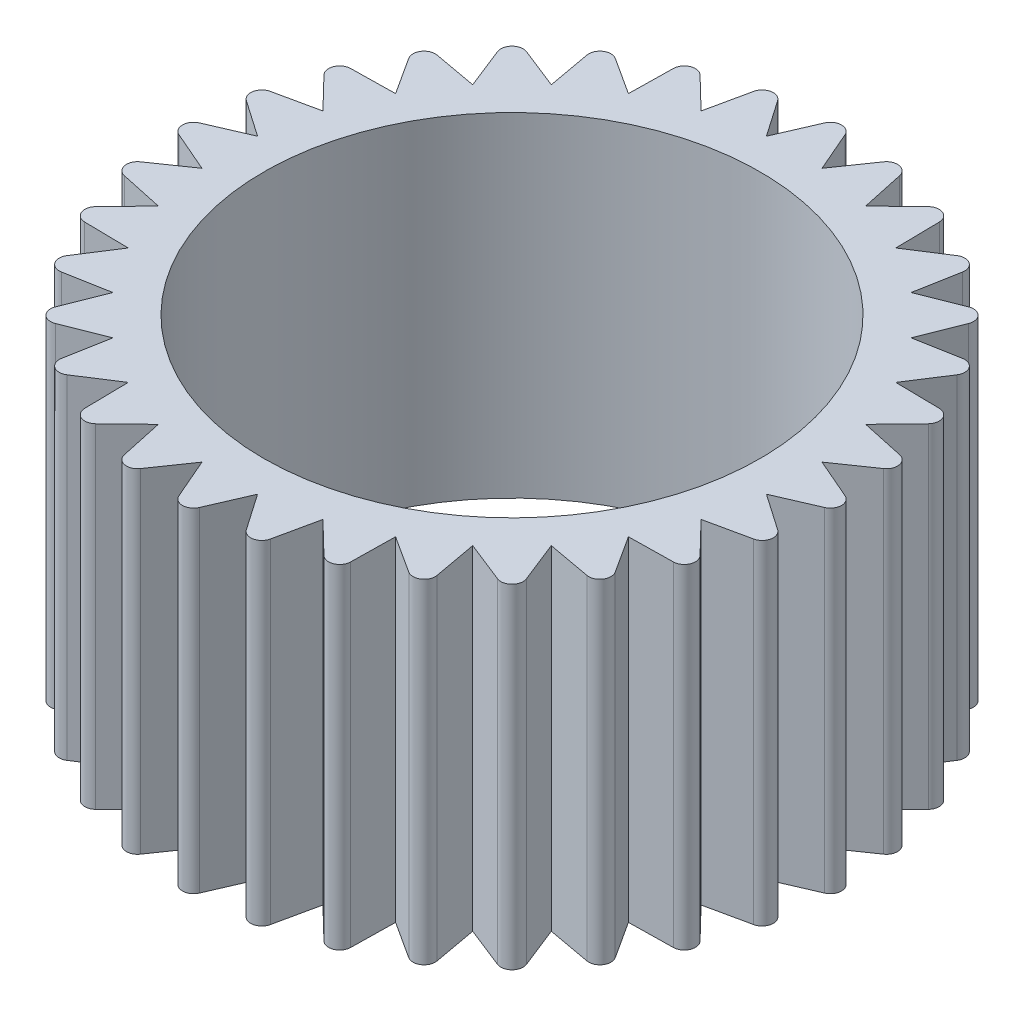
from build123d import *

# Parameters (mm, degrees)
SKETCH1_R           = 11.15
BOSS_EXTRUDE1_DEPTH = 15
FILLET1_R           = 0.5


with BuildPart() as part:
    # Sketch1 → Boss-Extrude1 (new body)
    with BuildSketch(Plane(origin=(0, 0, 0), x_dir=(1, 0, 0), z_dir=(0, 1, 0))):
        Polygon((0, 15.55956659), (-1.24854043, 12.676643718), (-3.035520856, 15.260593881), (-3.69764058, 12.189487409), (-5.954388349, 14.375165107), (-6.004642477, 11.233895935), (-8.644432036, 12.9373068), (-8.080889331, 9.84659214), (-11.002275048, 11.002275048), (-9.84659214, 8.080889331), (-12.9373068, 8.644432036), (-11.233895935, 6.004642477), (-14.375165107, 5.954388349), (-12.189487409, 3.69764058), (-15.260593881, 3.035520856), (-12.676643718, 1.24854043), (-15.55956659, 0), (-12.676643718, -1.24854043), (-15.260593881, -3.035520856), (-12.189487409, -3.69764058), (-14.375165107, -5.954388349), (-11.233895935, -6.004642477), (-12.9373068, -8.644432036), (-9.84659214, -8.080889331), (-11.002275048, -11.002275048), (-8.080889331, -9.84659214), (-8.644432036, -12.9373068), (-6.004642477, -11.233895935), (-5.954388349, -14.375165107), (-3.69764058, -12.189487409), (-3.035520856, -15.260593881), (-1.24854043, -12.676643718), (0, -15.55956659), (1.24854043, -12.676643718), (3.035520856, -15.260593881), (3.69764058, -12.189487409), (5.954388349, -14.375165107), (6.004642477, -11.233895935), (8.644432036, -12.9373068), (8.080889331, -9.84659214), (11.002275048, -11.002275048), (9.84659214, -8.080889331), (12.9373068, -8.644432036), (11.233895935, -6.004642477), (14.375165107, -5.954388349), (12.189487409, -3.69764058), (15.260593881, -3.035520856), (12.676643718, -1.24854043), (15.55956659, 0), (12.676643718, 1.24854043), (15.260593881, 3.035520856), (12.189487409, 3.69764058), (14.375165107, 5.954388349), (11.233895935, 6.004642477), (12.9373068, 8.644432036), (9.84659214, 8.080889331), (11.002275048, 11.002275048), (8.080889331, 9.84659214), (8.644432036, 12.9373068), (6.004642477, 11.233895935), (5.954388349, 14.375165107), (3.69764058, 12.189487409), (3.035520856, 15.260593881), (1.24854043, 12.676643718), align=None)
        Circle(SKETCH1_R, mode=Mode.SUBTRACT)
    extrude(amount=BOSS_EXTRUDE1_DEPTH)

    # Fillet1
    fillet1_edges = [part.edges().sort_by_distance(p)[0] for p in [
        (0, 7.5, -15.55956659),
        (3.035520856, 7.5, -15.260593881),
        (5.954388349, 7.5, -14.375165107),
        (8.644432036, 7.5, -12.9373068),
        (11.002275048, 7.5, -11.002275048),
        (12.9373068, 7.5, -8.644432036),
        (14.375165107, 7.5, -5.954388349),
        (15.260593881, 7.5, -3.035520856),
        (15.55956659, 7.5, 0),
        (15.260593881, 7.5, 3.035520856),
        (14.375165107, 7.5, 5.954388349),
        (12.9373068, 7.5, 8.644432036),
        (11.002275048, 7.5, 11.002275048),
        (8.644432036, 7.5, 12.9373068),
        (5.954388349, 7.5, 14.375165107),
        (3.035520856, 7.5, 15.260593881),
        (0, 7.5, 15.55956659),
        (-3.035520856, 7.5, 15.260593881),
        (-5.954388349, 7.5, 14.375165107),
        (-8.644432036, 7.5, 12.9373068),
        (-11.002275048, 7.5, 11.002275048),
        (-12.9373068, 7.5, 8.644432036),
        (-14.375165107, 7.5, 5.954388349),
        (-15.260593881, 7.5, 3.035520856),
        (-15.55956659, 7.5, 0),
        (-15.260593881, 7.5, -3.035520856),
        (-14.375165107, 7.5, -5.954388349),
        (-12.9373068, 7.5, -8.644432036),
        (-11.002275048, 7.5, -11.002275048),
        (-8.644432036, 7.5, -12.9373068),
        (-5.954388349, 7.5, -14.375165107),
        (-3.035520856, 7.5, -15.260593881),
    ]]
    fillet(fillet1_edges, radius=FILLET1_R)


solid = part.part
